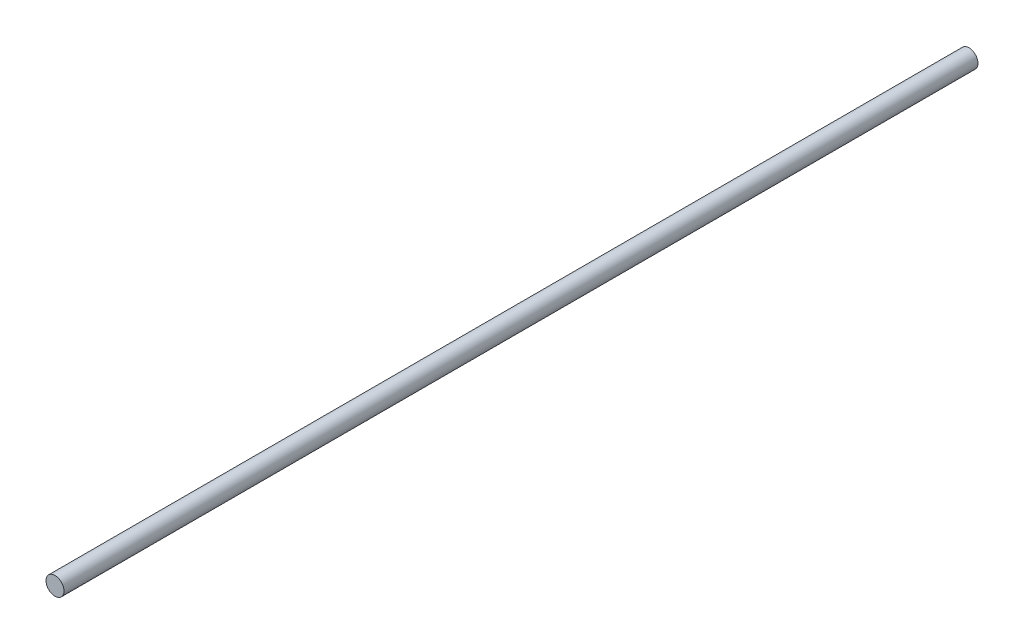
from build123d import *

# Parameters (mm, degrees)
SKETCH2_W = 405.8
SKETCH2_H = 4


with BuildPart() as part:
    # Sketch2 → Revolve1 (revolve)
    with BuildSketch(Plane(origin=(0, 0, 0), x_dir=(0, 0, -1), z_dir=(1, 0, 0))):
        with Locations((130, 2)):
            Rectangle(SKETCH2_W, SKETCH2_H)
    revolve(axis=Axis((0, 0, 72.9), (0, 0, -1)))


solid = part.part
